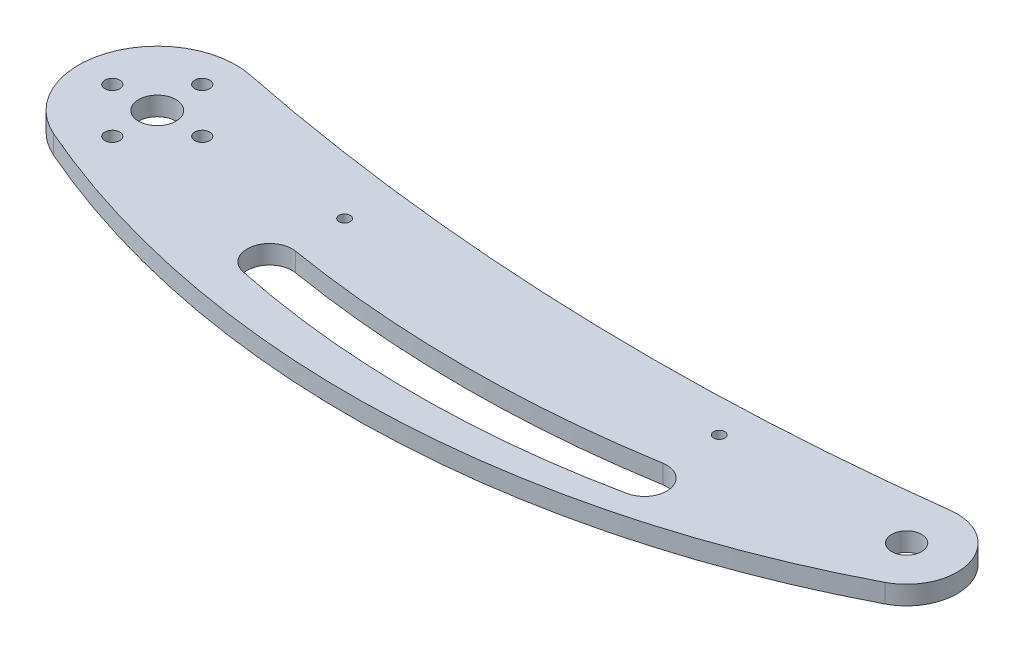
from build123d import *

# Parameters (mm, degrees)
SKETCH1_R           = 5
SKETCH1_R_2         = 2
SKETCH1_R_3         = 4
SKETCH1_R_4         = 1.5
BOSS_EXTRUDE1_DEPTH = 5


with BuildPart() as part:
    # Sketch1 → Boss-Extrude1 (new body)
    with BuildSketch(Plane(origin=(0, 0, 0), x_dir=(1, 0, 0), z_dir=(0, 1, 0))):
        with BuildLine():
            ThreePointArc((4.164387077, 20.582951204), (-20.032105437, 6.301964119), (-8.369909934, -19.259922318))
            ThreePointArc((-8.369909934, -19.259922318), (99.738576714, -39.831721611), (206.206468023, -11.98873449))
            ThreePointArc((206.206468023, -11.98873449), (212.890441324, 4.010800728), (198.30885544, 13.393656337))
            ThreePointArc((198.30885544, 13.393656337), (100.943706101, 9.078229318), (4.164387077, 20.582951204))
        make_face()
        Circle(SKETCH1_R, mode=Mode.SUBTRACT)
        with Locations((0, 12)):
            Circle(SKETCH1_R_2, mode=Mode.SUBTRACT)
        with Locations((12, 0)):
            Circle(SKETCH1_R_2, mode=Mode.SUBTRACT)
        with Locations((0, -12)):
            Circle(SKETCH1_R_2, mode=Mode.SUBTRACT)
        with Locations((-12, 0)):
            Circle(SKETCH1_R_2, mode=Mode.SUBTRACT)
        with Locations((200, 0)):
            Circle(SKETCH1_R_3, mode=Mode.SUBTRACT)
        with Locations((50, 0)):
            Circle(SKETCH1_R_4, mode=Mode.SUBTRACT)
        with Locations((150, 0)):
            Circle(SKETCH1_R_4, mode=Mode.SUBTRACT)
        with BuildLine():
            ThreePointArc((151.229508397, -25.872674783), (155.897333295, -18.894803181), (149.019607843, -14.08063929))
            ThreePointArc((149.019607843, -14.08063929), (100, -18.112603774), (50.980392157, -14.08063929))
            ThreePointArc((50.980392157, -14.08063929), (44.102666705, -18.894803181), (48.770491603, -25.872674783))
            ThreePointArc((48.770491603, -25.872674783), (100, -31.177890471), (151.229508397, -25.872674783))
        make_face(mode=Mode.SUBTRACT)
    extrude(amount=BOSS_EXTRUDE1_DEPTH)


solid = part.part
